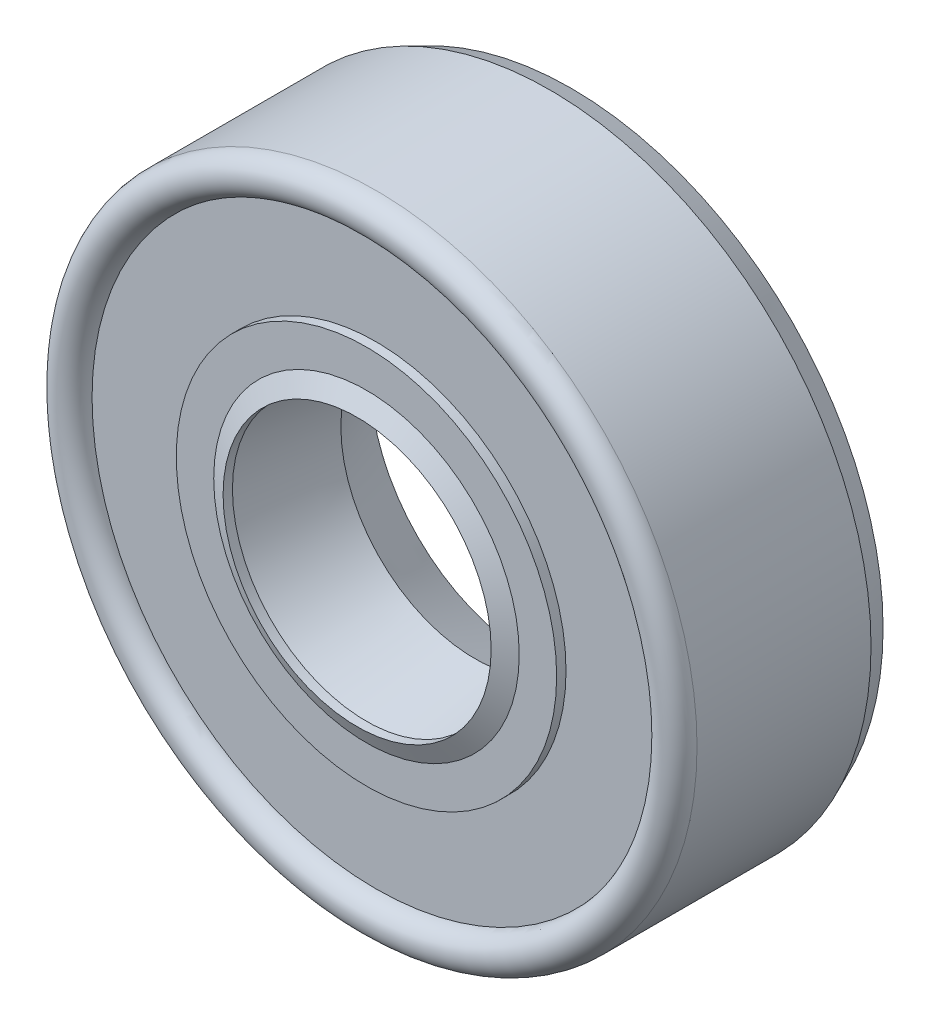
from build123d import *

# Parameters (mm, degrees)
SKETCH2_R = 0.55499


with BuildPart() as part:
    # Sketch1 → Revolve1 (revolve)
    with BuildSketch(Plane(origin=(0, 0, 0), x_dir=(0, 0, -1), z_dir=(1, 0, 0))):
        with BuildLine():
            Line((-3.134995, 3.9751), (-2.8575, 3.9751))
            Line((-2.8575, 3.9751), (-2.580005, 4.53009))
            Line((-2.580005, 4.53009), (0.357505, 3.9751))
            Line((0.357505, 3.9751), (2.06375, 4.807585))
            Line((2.06375, 4.807585), (2.06375, 5.08508))
            Line((2.06375, 5.08508), (0.912495, 5.08508))
            ThreePointArc((0.912495, 5.08508), (0.357505, 4.53009), (-0.197485, 5.08508))
            Line((-0.197485, 5.08508), (-2.025015, 5.08508))
            Line((-2.025015, 5.08508), (-2.025015, 8.97001))
            Line((-2.025015, 8.97001), (1.945005, 8.97001))
            Line((1.945005, 8.97001), (1.945005, 9.1087575))
            Line((1.945005, 9.1087575), (2.580005, 9.1087575))
            Line((2.580005, 9.1087575), (2.580005, 8.97001))
            Line((2.580005, 8.97001), (3.215005, 8.97001))
            Line((3.215005, 8.97001), (3.215005, 9.247505))
            Line((3.215005, 9.247505), (2.580005, 9.525))
            Line((2.580005, 9.525), (-2.580005, 9.525))
            ThreePointArc((-2.580005, 9.525), (-3.134995, 8.97001), (-2.580005, 8.41502))
            Line((-2.580005, 8.41502), (-2.580005, 5.64007))
            Line((-2.580005, 5.64007), (-2.8575, 5.64007))
            Line((-2.8575, 5.64007), (-2.8575, 4.53009))
            Line((-2.8575, 4.53009), (-3.134995, 3.9751))
        make_face()
    revolve(axis=Axis((0, 0, -3.134995), (0, 0, 1)))


with BuildPart() as body_2:
    # Sketch2 → Revolve2 (revolve)
    with BuildSketch(Plane(origin=(0, 0, 0), x_dir=(0, 0, -1), z_dir=(1, 0, 0))):
        with Locations((0.357505, 5.08508)):
            Circle(SKETCH2_R)
    revolve(axis=Axis((0, 0, 3.134995), (0, 0, -1)))


solid = Compound([part.part, body_2.part])
